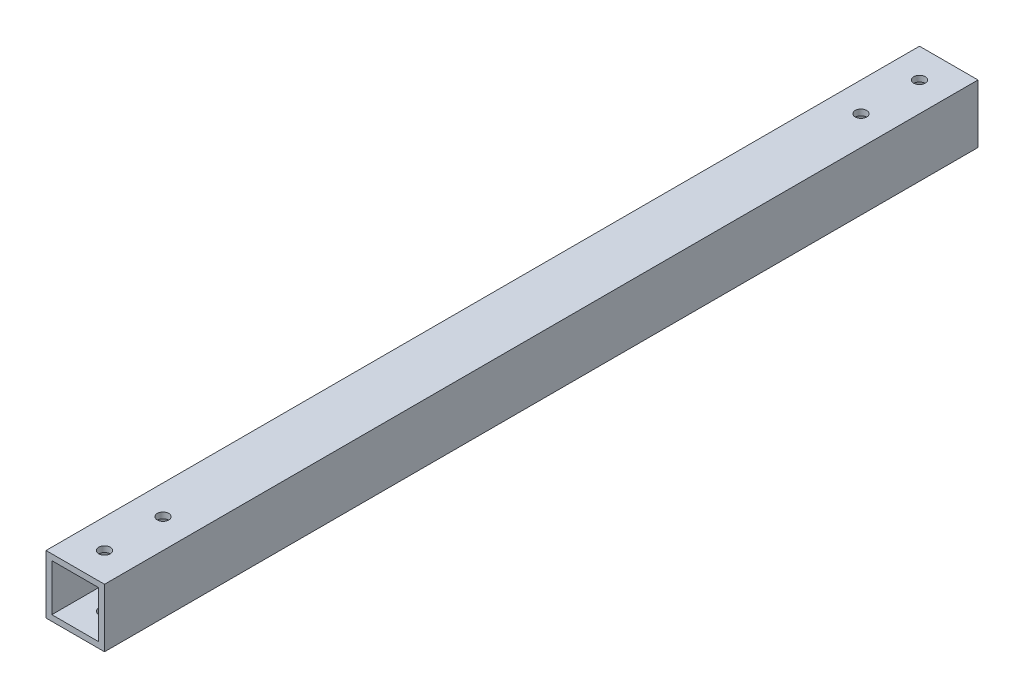
from build123d import *

# Parameters (mm, degrees)
SKETCH1_W           = 25.4
SKETCH1_H           = 25.4
SKETCH1_W_2         = 20.32
SKETCH1_H_2         = 20.32
EXTRUDE_THIN1_DEPTH = 189.58179
SKETCH2_R           = 2.4892
CUT_EXTRUDE1_DEPTH  = 26.4


with BuildPart() as part:
    # Sketch1 → Extrude-Thin1 (new body, symmetric)
    with BuildSketch(Plane.XY):
        with Locations((12.7, 12.7)):
            Rectangle(SKETCH1_W, SKETCH1_H)
        with Locations((12.7, 12.7)):
            Rectangle(SKETCH1_W_2, SKETCH1_H_2, mode=Mode.SUBTRACT)
    extrude(amount=EXTRUDE_THIN1_DEPTH, both=True)

    # Sketch2 → Cut-Extrude1 (cut, through all)
    with BuildSketch(Plane(origin=(0, 25.4, 0), x_dir=(1, 0, 0), z_dir=(0, 1, 0))):
        with Locations((12.7, -176.88179)):
            Circle(SKETCH2_R)
        with Locations((12.7, -151.48179)):
            Circle(SKETCH2_R)
        with Locations((12.7, 176.88179)):
            Circle(SKETCH2_R)
        with Locations((12.7, 151.48179)):
            Circle(SKETCH2_R)
    extrude(amount=-CUT_EXTRUDE1_DEPTH, mode=Mode.SUBTRACT)


solid = part.part
